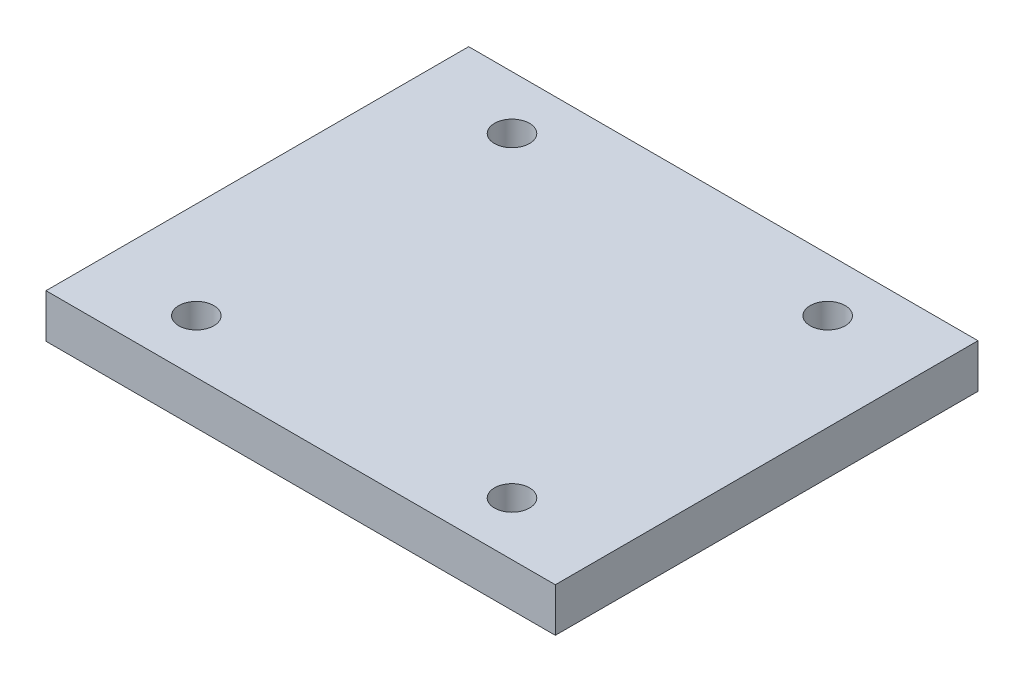
from build123d import *

# Parameters (mm, degrees)
SKETCH1_W           = 29.04
SKETCH1_H           = 23.1
SKETCH1_R           = 1
BOSS_EXTRUDE1_DEPTH = 2.5
SKETCH2_W           = 29.04
SKETCH2_H           = 2.5
BOSS_EXTRUDE2_DEPTH = 0.5
SKETCH3_W           = 29.04
SKETCH3_H           = 2.5
BOSS_EXTRUDE3_DEPTH = 0.5


with BuildPart() as part:
    # Sketch1 → Boss-Extrude1 (new body)
    with BuildSketch(Plane(origin=(0, 0, 0), x_dir=(1, 0, 0), z_dir=(0, 1, 0))):
        with Locations((-0.98, -0.45)):
            Rectangle(SKETCH1_W, SKETCH1_H)
        with Locations((-9.98, 8.55)):
            Circle(SKETCH1_R, mode=Mode.SUBTRACT)
        with Locations((8.02, 8.55)):
            Circle(SKETCH1_R, mode=Mode.SUBTRACT)
        with Locations((8.02, -9.45)):
            Circle(SKETCH1_R, mode=Mode.SUBTRACT)
        with Locations((-9.98, -9.45)):
            Circle(SKETCH1_R, mode=Mode.SUBTRACT)
    extrude(amount=BOSS_EXTRUDE1_DEPTH)

    # Sketch2 → Boss-Extrude2 (add)
    with BuildSketch(Plane(origin=(0, 0, -11.1), x_dir=(-1, 0, 0), z_dir=(0, 0, -1))):
        with Locations((0.98, 1.25)):
            Rectangle(SKETCH2_W, SKETCH2_H)
    extrude(amount=BOSS_EXTRUDE2_DEPTH)

    # Sketch3 → Boss-Extrude3 (add)
    with BuildSketch(Plane.XY.offset(12)):
        with Locations((-0.98, 1.25)):
            Rectangle(SKETCH3_W, SKETCH3_H)
    extrude(amount=BOSS_EXTRUDE3_DEPTH)


solid = part.part
